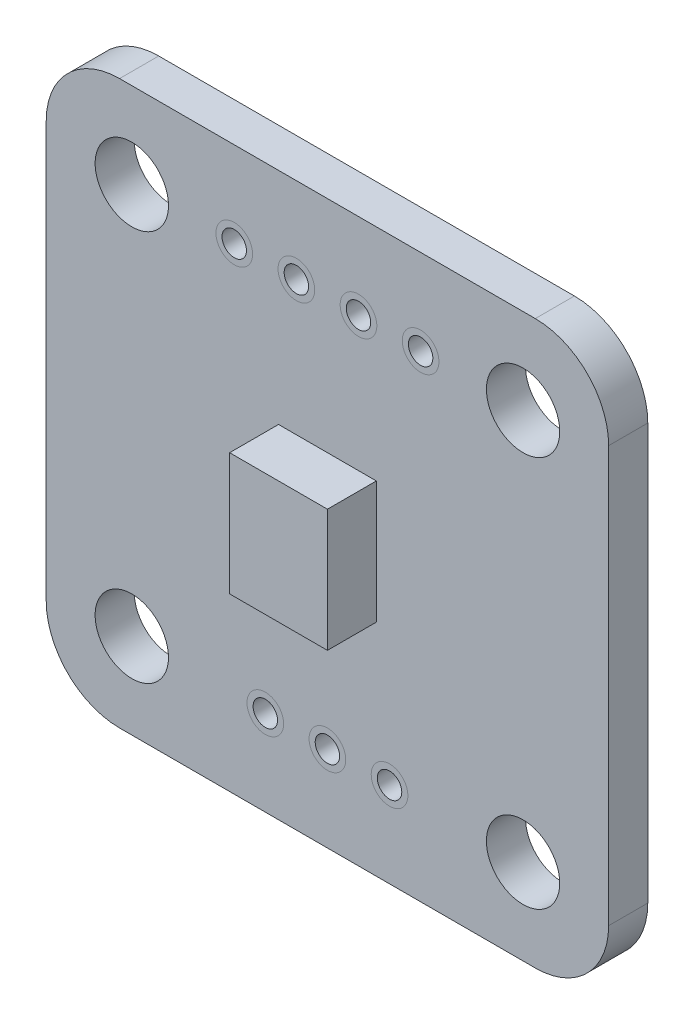
from build123d import *

# Parameters (mm, degrees)
SKETCH1_R           = 1.5
SKETCH1_R_2         = 0.5
BOSS_EXTRUDE1_DEPTH = 0.8
SKETCH2_W           = 4
SKETCH2_H           = 5
BOSS_EXTRUDE2_DEPTH = 2


with BuildPart() as part:
    # Sketch1 → Boss-Extrude1 (new body, symmetric)
    with BuildSketch(Plane.XY):
        with BuildLine():
            Line((-8.5, -11.5), (8.5, -11.5))
            ThreePointArc((8.5, -11.5), (10.621320344, -10.621320344), (11.5, -8.5))
            Line((11.5, -8.5), (11.5, 8.5))
            ThreePointArc((11.5, 8.5), (10.621320344, 10.621320344), (8.5, 11.5))
            Line((8.5, 11.5), (-8.5, 11.5))
            ThreePointArc((-8.5, 11.5), (-10.621320344, 10.621320344), (-11.5, 8.5))
            Line((-11.5, 8.5), (-11.5, -8.5))
            ThreePointArc((-11.5, -8.5), (-10.621320344, -10.621320344), (-8.5, -11.5))
        make_face()
        with Locations((-8, 8)):
            Circle(SKETCH1_R, mode=Mode.SUBTRACT)
        with Locations((8, 8)):
            Circle(SKETCH1_R, mode=Mode.SUBTRACT)
        with Locations((8, -8)):
            Circle(SKETCH1_R, mode=Mode.SUBTRACT)
        with Locations((-8, -8)):
            Circle(SKETCH1_R, mode=Mode.SUBTRACT)
        with Locations((0, -8)):
            Circle(SKETCH1_R_2, mode=Mode.SUBTRACT)
        with Locations((-2.54, -8)):
            Circle(SKETCH1_R_2, mode=Mode.SUBTRACT)
        with Locations((2.54, -8)):
            Circle(SKETCH1_R_2, mode=Mode.SUBTRACT)
        with Locations((-1.27, 8)):
            Circle(SKETCH1_R_2, mode=Mode.SUBTRACT)
        with Locations((1.27, 8)):
            Circle(SKETCH1_R_2, mode=Mode.SUBTRACT)
        with Locations((-3.81, 8)):
            Circle(SKETCH1_R_2, mode=Mode.SUBTRACT)
        with Locations((3.81, 8)):
            Circle(SKETCH1_R_2, mode=Mode.SUBTRACT)
    extrude(amount=BOSS_EXTRUDE1_DEPTH, both=True)

    # Sketch2 → Boss-Extrude2 (add)
    with BuildSketch(Plane.XY.offset(0.8)):
        Rectangle(SKETCH2_W, SKETCH2_H)
    extrude(amount=BOSS_EXTRUDE2_DEPTH)


solid = part.part
